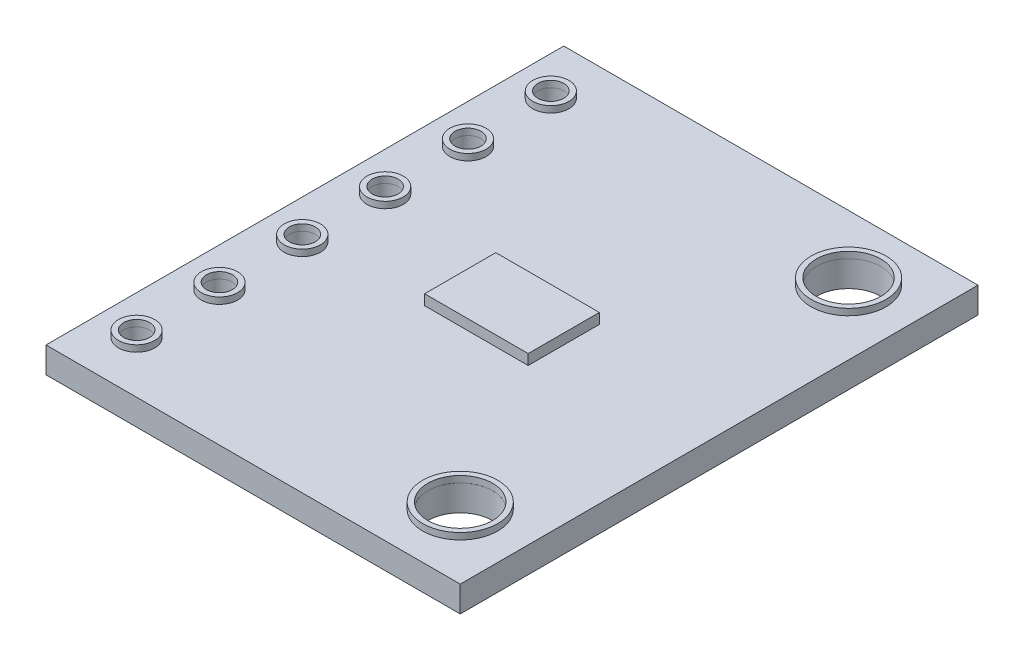
from build123d import *

# Parameters (mm, degrees)
SKETCH1_W             = 16
SKETCH1_H             = 20
BOSS_EXTRUDE1_DEPTH   = 1
SKETCH2_R             = 0.5
SKETCH2_R_2           = 1.25
CUT_EXTRUDE1_DEPTH    = 1
SKETCH3_R             = 1.45
SKETCH3_R_2           = 1.25
BOSS_EXTRUDE2_DEPTH   = 0.25
BOSS_EXTRUDE2_2_DEPTH = 0.25
SKETCH3_R_3           = 0.7
SKETCH3_R_4           = 0.5
BOSS_EXTRUDE2_3_DEPTH = 0.25
BOSS_EXTRUDE2_4_DEPTH = 0.25
BOSS_EXTRUDE2_5_DEPTH = 0.25
BOSS_EXTRUDE2_6_DEPTH = 0.25
BOSS_EXTRUDE2_7_DEPTH = 0.25
BOSS_EXTRUDE2_8_DEPTH = 0.25
SKETCH4_W             = 4
SKETCH4_H             = 2.75
BOSS_EXTRUDE3_DEPTH   = 0.4


with BuildPart() as part:
    # Sketch1 → Boss-Extrude1 (new body)
    with BuildSketch(Plane(origin=(0, 0, 0), x_dir=(1, 0, 0), z_dir=(0, 1, 0))):
        Rectangle(SKETCH1_W, SKETCH1_H)
    extrude(amount=BOSS_EXTRUDE1_DEPTH)

    # Sketch2 → Cut-Extrude1 (cut)
    with BuildSketch(Plane(origin=(0, 1, 0), x_dir=(1, 0, 0), z_dir=(0, 1, 0))):
        with Locations((-6.5, 8)):
            Circle(SKETCH2_R)
        with Locations((-6.5, 4.8)):
            Circle(SKETCH2_R)
        with Locations((-6.5, 1.6)):
            Circle(SKETCH2_R)
        with Locations((-6.5, -1.6)):
            Circle(SKETCH2_R)
        with Locations((-6.5, -4.8)):
            Circle(SKETCH2_R)
        with Locations((-6.5, -8)):
            Circle(SKETCH2_R)
        with Locations((5.5, 7.5)):
            Circle(SKETCH2_R_2)
        with Locations((5.5, -7.5)):
            Circle(SKETCH2_R_2)
    extrude(amount=-CUT_EXTRUDE1_DEPTH, mode=Mode.SUBTRACT)


with BuildPart() as body_2:
    # Sketch3 → Boss-Extrude2 (new body)
    with BuildSketch(Plane(origin=(0, 1, 0), x_dir=(1, 0, 0), z_dir=(0, 1, 0))):
        with Locations((5.5, -7.5)):
            Circle(SKETCH3_R)
        with Locations((5.5, -7.5)):
            Circle(SKETCH3_R_2, mode=Mode.SUBTRACT)
    extrude(amount=BOSS_EXTRUDE2_DEPTH)


with BuildPart() as body_3:
    # Sketch3 → Boss-Extrude2 2 (new body)
    with BuildSketch(Plane(origin=(0, 1, 0), x_dir=(1, 0, 0), z_dir=(0, 1, 0))):
        with Locations((5.5, 7.5)):
            Circle(SKETCH3_R)
        with Locations((5.5, 7.5)):
            Circle(SKETCH3_R_2, mode=Mode.SUBTRACT)
    extrude(amount=BOSS_EXTRUDE2_2_DEPTH)


with BuildPart() as body_4:
    # Sketch3 → Boss-Extrude2 3 (new body)
    with BuildSketch(Plane(origin=(0, 1, 0), x_dir=(1, 0, 0), z_dir=(0, 1, 0))):
        with Locations((-6.5, -8)):
            Circle(SKETCH3_R_3)
        with Locations((-6.5, -8)):
            Circle(SKETCH3_R_4, mode=Mode.SUBTRACT)
    extrude(amount=BOSS_EXTRUDE2_3_DEPTH)


with BuildPart() as body_5:
    # Sketch3 → Boss-Extrude2 4 (new body)
    with BuildSketch(Plane(origin=(0, 1, 0), x_dir=(1, 0, 0), z_dir=(0, 1, 0))):
        with Locations((-6.5, -4.8)):
            Circle(SKETCH3_R_3)
        with Locations((-6.5, -4.8)):
            Circle(SKETCH3_R_4, mode=Mode.SUBTRACT)
    extrude(amount=BOSS_EXTRUDE2_4_DEPTH)


with BuildPart() as body_6:
    # Sketch3 → Boss-Extrude2 5 (new body)
    with BuildSketch(Plane(origin=(0, 1, 0), x_dir=(1, 0, 0), z_dir=(0, 1, 0))):
        with Locations((-6.5, -1.6)):
            Circle(SKETCH3_R_3)
        with Locations((-6.5, -1.6)):
            Circle(SKETCH3_R_4, mode=Mode.SUBTRACT)
    extrude(amount=BOSS_EXTRUDE2_5_DEPTH)


with BuildPart() as body_7:
    # Sketch3 → Boss-Extrude2 6 (new body)
    with BuildSketch(Plane(origin=(0, 1, 0), x_dir=(1, 0, 0), z_dir=(0, 1, 0))):
        with Locations((-6.5, 1.6)):
            Circle(SKETCH3_R_3)
        with Locations((-6.5, 1.6)):
            Circle(SKETCH3_R_4, mode=Mode.SUBTRACT)
    extrude(amount=BOSS_EXTRUDE2_6_DEPTH)


with BuildPart() as body_8:
    # Sketch3 → Boss-Extrude2 7 (new body)
    with BuildSketch(Plane(origin=(0, 1, 0), x_dir=(1, 0, 0), z_dir=(0, 1, 0))):
        with Locations((-6.5, 4.8)):
            Circle(SKETCH3_R_3)
        with Locations((-6.5, 4.8)):
            Circle(SKETCH3_R_4, mode=Mode.SUBTRACT)
    extrude(amount=BOSS_EXTRUDE2_7_DEPTH)


with BuildPart() as body_9:
    # Sketch3 → Boss-Extrude2 8 (new body)
    with BuildSketch(Plane(origin=(0, 1, 0), x_dir=(1, 0, 0), z_dir=(0, 1, 0))):
        with Locations((-6.5, 8)):
            Circle(SKETCH3_R_3)
        with Locations((-6.5, 8)):
            Circle(SKETCH3_R_4, mode=Mode.SUBTRACT)
    extrude(amount=BOSS_EXTRUDE2_8_DEPTH)


with BuildPart() as body_10:
    # Sketch4 → Boss-Extrude3 (new body)
    with BuildSketch(Plane(origin=(0, 1, 0), x_dir=(1, 0, 0), z_dir=(0, 1, 0))):
        Rectangle(SKETCH4_W, SKETCH4_H)
    extrude(amount=BOSS_EXTRUDE3_DEPTH)


solid = Compound([part.part, body_2.part, body_3.part, body_4.part, body_5.part, body_6.part, body_7.part, body_8.part, body_9.part, body_10.part])
